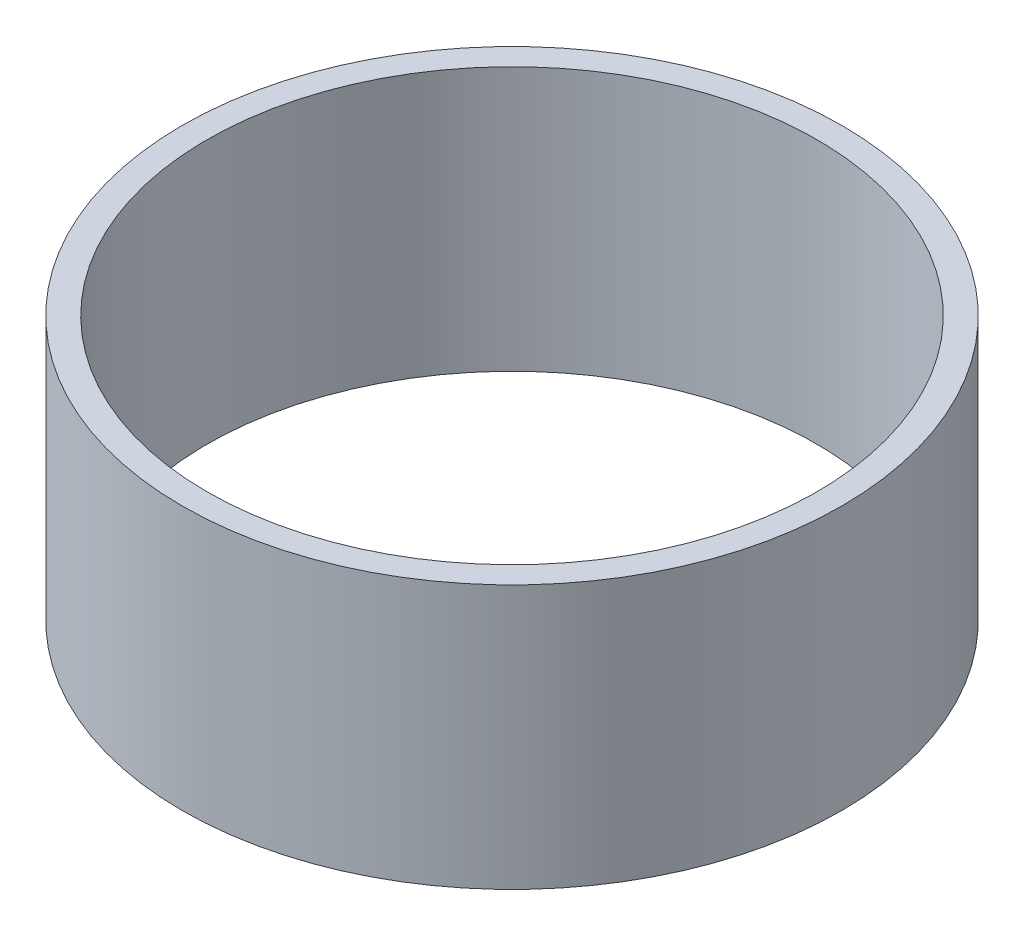
from build123d import *

# Parameters (mm, degrees)
SKETCH1_R      = 63.5
SKETCH1_R_2    = 58.7375
EXTRUDE1_DEPTH = 50.8


with BuildPart() as part:
    # Sketch1 → Extrude1 (new body)
    with BuildSketch(Plane(origin=(0, 0, 0), x_dir=(1, 0, 0), z_dir=(0, 1, 0))):
        Circle(SKETCH1_R)
        Circle(SKETCH1_R_2, mode=Mode.SUBTRACT)
    extrude(amount=EXTRUDE1_DEPTH)


solid = part.part
